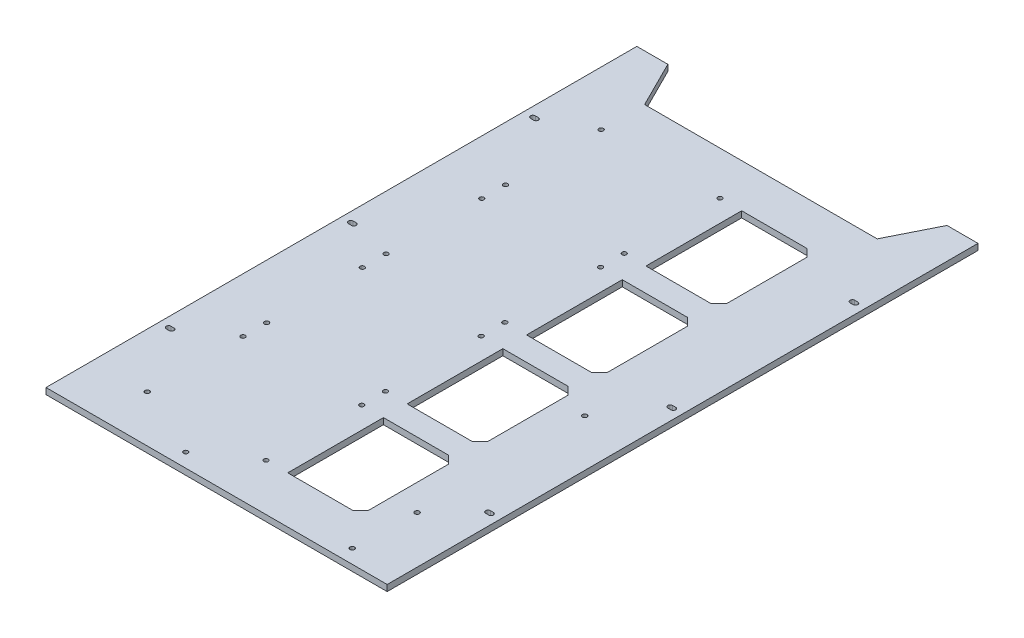
from build123d import *

# Parameters (mm, degrees)
SKETCH_1_R      = 1.5
SKETCH_1_R_2    = 1.45
EXTRUDE_1_DEPTH = 4


with BuildPart() as part:
    # 草圖1 → 填料-伸長1 (new body)
    with BuildSketch(Plane(origin=(0, 4, 0), x_dir=(1, 0, 0), z_dir=(0, 1, 0))):
        Polygon((-75, 160.5), (-90, 190.5), (-110, 190.5), (-110, -190.5), (110, -190.5), (110, 190.5), (90, 190.5), (75, 160.5), align=None)
        with Locations((79.5, -32.625)):
            Circle(SKETCH_1_R, mode=Mode.SUBTRACT)
        with Locations((79.5, -140.625)):
            Circle(SKETCH_1_R, mode=Mode.SUBTRACT)
        with Locations((-75, 132.5)):
            Circle(SKETCH_1_R_2, mode=Mode.SUBTRACT)
        with Locations((1.6, 132.5)):
            Circle(SKETCH_1_R_2, mode=Mode.SUBTRACT)
        with Locations((-75, 70.78)):
            Circle(SKETCH_1_R_2, mode=Mode.SUBTRACT)
        with Locations((1.6, 70.78)):
            Circle(SKETCH_1_R_2, mode=Mode.SUBTRACT)
        with Locations((1.6, 55.5)):
            Circle(SKETCH_1_R_2, mode=Mode.SUBTRACT)
        with Locations((-75, 55.5)):
            Circle(SKETCH_1_R_2, mode=Mode.SUBTRACT)
        with Locations((-75, -6.22)):
            Circle(SKETCH_1_R_2, mode=Mode.SUBTRACT)
        with Locations((1.6, -6.22)):
            Circle(SKETCH_1_R_2, mode=Mode.SUBTRACT)
        with Locations((-75, -21.5)):
            Circle(SKETCH_1_R_2, mode=Mode.SUBTRACT)
        with Locations((1.6, -21.5)):
            Circle(SKETCH_1_R_2, mode=Mode.SUBTRACT)
        with Locations((-75, -83.22)):
            Circle(SKETCH_1_R_2, mode=Mode.SUBTRACT)
        with Locations((1.6, -83.22)):
            Circle(SKETCH_1_R_2, mode=Mode.SUBTRACT)
        with Locations((1.6, -98.5)):
            Circle(SKETCH_1_R_2, mode=Mode.SUBTRACT)
        with Locations((-75, -98.5)):
            Circle(SKETCH_1_R_2, mode=Mode.SUBTRACT)
        with Locations((-75, -160.22)):
            Circle(SKETCH_1_R_2, mode=Mode.SUBTRACT)
        with Locations((1.6, -160.22)):
            Circle(SKETCH_1_R_2, mode=Mode.SUBTRACT)
        with Locations((-28.86, -181.5)):
            Circle(SKETCH_1_R_2, mode=Mode.SUBTRACT)
        with Locations((78.5, -181.5)):
            Circle(SKETCH_1_R_2, mode=Mode.SUBTRACT)
        with BuildLine():
            Line((-104, 1.5), (-102, 1.5))
            ThreePointArc((-102, 1.5), (-100.5, 0), (-102, -1.5))
            Line((-102, -1.5), (-104, -1.5))
            ThreePointArc((-104, -1.5), (-105.5, 0), (-104, 1.5))
        make_face(mode=Mode.SUBTRACT)
        with BuildLine():
            Line((102, -116), (104, -116))
            ThreePointArc((104, -116), (105.5, -117.5), (104, -119))
            Line((104, -119), (102, -119))
            ThreePointArc((102, -119), (100.5, -117.5), (102, -116))
        make_face(mode=Mode.SUBTRACT)
        with BuildLine():
            Line((102, 1.5), (104, 1.5))
            ThreePointArc((104, 1.5), (105.5, 0), (104, -1.5))
            Line((104, -1.5), (102, -1.5))
            ThreePointArc((102, -1.5), (100.5, 0), (102, 1.5))
        make_face(mode=Mode.SUBTRACT)
        with BuildLine():
            Line((102, 119), (104, 119))
            ThreePointArc((104, 119), (105.5, 117.5), (104, 116))
            Line((104, 116), (102, 116))
            ThreePointArc((102, 116), (100.5, 117.5), (102, 119))
        make_face(mode=Mode.SUBTRACT)
        with BuildLine():
            Line((-104, -116), (-102, -116))
            ThreePointArc((-102, -116), (-100.5, -117.5), (-102, -119))
            Line((-102, -119), (-104, -119))
            ThreePointArc((-104, -119), (-105.5, -117.5), (-104, -116))
        make_face(mode=Mode.SUBTRACT)
        with BuildLine():
            Line((-104, 119), (-102, 119))
            ThreePointArc((-102, 119), (-100.5, 117.5), (-102, 116))
            Line((-102, 116), (-104, 116))
            ThreePointArc((-104, 116), (-105.5, 117.5), (-104, 119))
        make_face(mode=Mode.SUBTRACT)
        Polygon((15.6, 132.5), (57.6, 132.5), (62.6, 127.5), (62.6, 75.78), (57.6, 70.78), (15.6, 70.78), align=None, mode=Mode.SUBTRACT)
        Polygon((57.6, 55.5), (62.6, 50.5), (62.6, -1.22), (57.6, -6.22), (15.6, -6.22), (15.6, 55.5), align=None, mode=Mode.SUBTRACT)
        Polygon((57.6, -21.5), (62.6, -26.5), (62.6, -78.22), (57.6, -83.22), (15.6, -83.22), (15.6, -21.5), align=None, mode=Mode.SUBTRACT)
        Polygon((57.6, -98.5), (62.6, -103.5), (62.6, -155.22), (57.6, -160.22), (15.6, -160.22), (15.6, -98.5), align=None, mode=Mode.SUBTRACT)
    extrude(amount=-EXTRUDE_1_DEPTH)


solid = part.part
